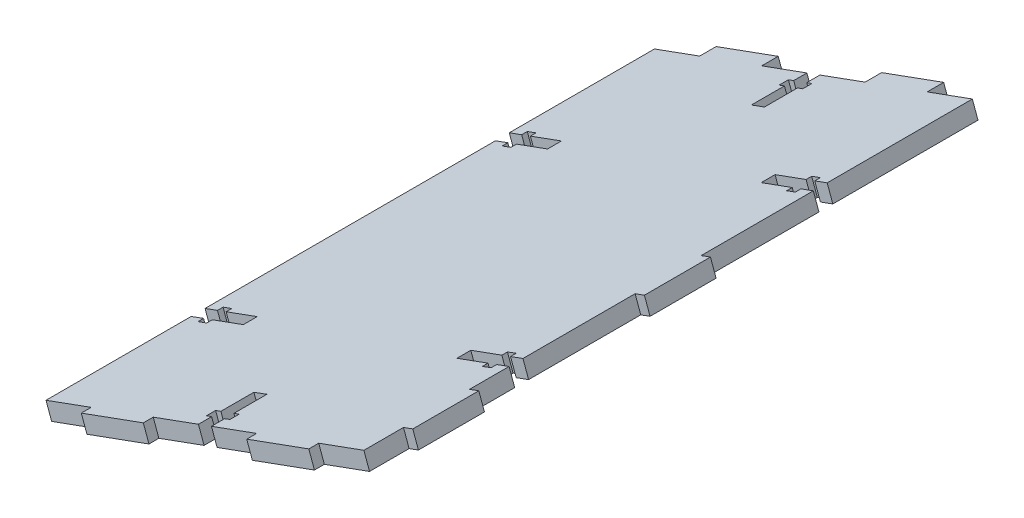
from build123d import *

# Parameters (mm, degrees)
BOSS_EXTRUDE1_DEPTH = 184.3
CUT_EXTRUDE3_DEPTH  = 38.907676661
SKETCH5_W           = 20
SKETCH5_H           = 5
SKETCH5_W_2         = 3
SKETCH5_H_2         = 20
SKETCH5_H_3         = 3
BOSS_EXTRUDE2_DEPTH = 5


with BuildPart() as part:
    # Sketch2 → Boss-Extrude1 (new body)
    with BuildSketch(Plane.XY.offset(34.9)):
        Polygon((-52.961538618, -36.862052104), (-51.252736373, -41.56098761), (-147.541457764, -76.577085001), (-149.250260009, -71.878149495), align=None)
    extrude(amount=BOSS_EXTRUDE1_DEPTH)

    # Sketch4 → Cut-Extrude3 (cut, through all)
    with BuildSketch(Plane(origin=(7.362313595, -20.245196221, 0), x_dir=(-0.939787101, -0.341760449, 0), z_dir=(0.341760449, -0.939787101, 0))):
        Polygon((111.499570088, -34.9), (115.699570088, -34.9), (115.699570088, -38.9), (117.399570088, -38.9), (117.399570088, -41.7), (115.699570088, -41.7), (115.699570088, -51.7), (111.499570088, -51.7), (111.499570088, -41.7), (109.799570088, -41.7), (109.799570088, -38.9), (111.499570088, -38.9), align=None)
        Polygon((62.37056233, -83.075), (62.37056233, -78.875), (66.37056233, -78.875), (66.37056233, -77.175), (69.17056233, -77.175), (69.17056233, -78.875), (79.17056233, -78.875), (79.17056233, -83.075), (69.17056233, -83.075), (69.17056233, -84.775), (66.37056233, -84.775), (66.37056233, -83.075), align=None)
        Polygon((115.699570088, -219.2), (111.499570088, -219.2), (111.499570088, -215.2), (109.799570088, -215.2), (109.799570088, -212.4), (111.499570088, -212.4), (111.499570088, -202.4), (115.699570088, -202.4), (115.699570088, -212.4), (117.399570088, -212.4), (117.399570088, -215.2), (115.699570088, -215.2), align=None)
        Polygon((66.37056233, -175.225), (66.37056233, -176.925), (69.17056233, -176.925), (69.17056233, -175.225), (79.17056233, -175.225), (79.17056233, -171.025), (69.17056233, -171.025), (69.17056233, -169.325), (66.37056233, -169.325), (66.37056233, -171.025), (62.37056233, -171.025), (62.37056233, -175.225), align=None)
        Polygon((164.828577846, -171.025), (164.828577846, -175.225), (160.828577846, -175.225), (160.828577846, -176.925), (158.028577846, -176.925), (158.028577846, -175.225), (148.028577846, -175.225), (148.028577846, -171.025), (158.028577846, -171.025), (158.028577846, -169.325), (160.828577846, -169.325), (160.828577846, -171.025), align=None)
        Polygon((160.828577846, -78.875), (160.828577846, -77.175), (158.028577846, -77.175), (158.028577846, -78.875), (148.028577846, -78.875), (148.028577846, -83.075), (158.028577846, -83.075), (158.028577846, -84.775), (160.828577846, -84.775), (160.828577846, -83.075), (164.828577846, -83.075), (164.828577846, -78.875), align=None)
    extrude(amount=-CUT_EXTRUDE3_DEPTH, mode=Mode.SUBTRACT)

    # Sketch5 → Boss-Extrude2 (add)
    with BuildSketch(Plane(origin=(7.362313595, -20.245196221, 0), x_dir=(0.939787101, 0.341760449, 0), z_dir=(0.341760449, -0.939787101, 0))):
        with Locations((-86.935066209, 32.4)):
            Rectangle(SKETCH5_W, SKETCH5_H)
        with Locations((-140.264073967, 32.4)):
            Rectangle(SKETCH5_W, SKETCH5_H)
        with Locations((-60.87056233, 127.05)):
            Rectangle(SKETCH5_W_2, SKETCH5_H_2)
        with Locations((-60.87056233, 197.2125)):
            Rectangle(SKETCH5_W_2, SKETCH5_H_2)
        with Locations((-86.935066209, 220.7)):
            Rectangle(SKETCH5_W, SKETCH5_H_3)
        with Locations((-140.264073967, 220.7)):
            Rectangle(SKETCH5_W, SKETCH5_H_3)
    extrude(amount=-BOSS_EXTRUDE2_DEPTH)


solid = part.part
